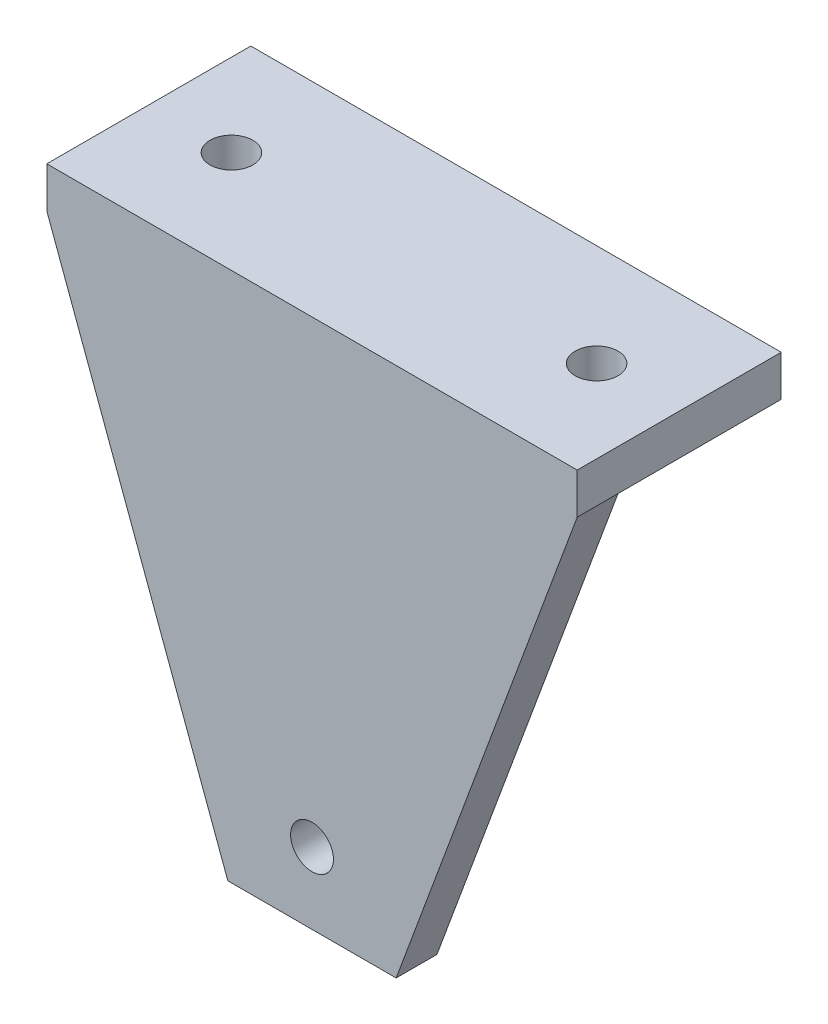
from build123d import *

# Parameters (mm, degrees)
SKETCH1_W           = 52
SKETCH1_H           = 20
SKETCH1_R           = 2.1
BOSS_EXTRUDE1_DEPTH = 4
SKETCH2_W           = 52
SKETCH2_H           = 4
BOSS_EXTRUDE2_DEPTH = 48
CUT_EXTRUDE1_REACH  = 22
SKETCH3_R           = 2.1
BOSS_EXTRUDE3_DEPTH = 16
CUT_EXTRUDE3_DEPTH  = 53


with BuildPart() as part:
    # Sketch1 → Boss-Extrude1 (new body)
    with BuildSketch(Plane(origin=(0, 0, 0), x_dir=(1, 0, 0), z_dir=(0, 1, 0))):
        with Locations((26, 10)):
            Rectangle(SKETCH1_W, SKETCH1_H)
        with Locations((43.9, 10)):
            Circle(SKETCH1_R, mode=Mode.SUBTRACT)
        with Locations((8.1, 10)):
            Circle(SKETCH1_R, mode=Mode.SUBTRACT)
    extrude(amount=BOSS_EXTRUDE1_DEPTH)

    # Sketch2 → Boss-Extrude2 (add)
    with BuildSketch(Plane.XZ):
        with Locations((26, -2)):
            Rectangle(SKETCH2_W, SKETCH2_H)
    extrude(amount=BOSS_EXTRUDE2_DEPTH)

    # Sketch3 → Cut-Extrude1 (cut, up to next)
    with BuildSketch(Plane.XY, mode=Mode.PRIVATE) as cut_extrude1_sk1:
        with Locations((26, -41)):
            Circle(SKETCH3_R)
    cut_extrude1_tool1 = extrude(cut_extrude1_sk1.sketch, amount=-CUT_EXTRUDE1_REACH, mode=Mode.PRIVATE) & part.part
    add(cut_extrude1_tool1.solids().sort_by_distance((26, -41, 0))[0], mode=Mode.SUBTRACT)
    # Sketch3 → Cut-Extrude1 (cut, up to next)
    with BuildSketch(Plane.XY, mode=Mode.PRIVATE) as cut_extrude1_sk2:
        Polygon((52, 0), (34.25, -48), (52, -48), align=None)
    cut_extrude1_tool2 = extrude(cut_extrude1_sk2.sketch, amount=-CUT_EXTRUDE1_REACH, mode=Mode.PRIVATE) & part.part
    add(cut_extrude1_tool2.solids().sort_by_distance((46.083333, -32, 0))[0], mode=Mode.SUBTRACT)
    # Sketch3 → Cut-Extrude1 (cut, up to next)
    with BuildSketch(Plane.XY, mode=Mode.PRIVATE) as cut_extrude1_sk3:
        Polygon((0, -48), (0, 0), (17.75, -48), align=None)
    cut_extrude1_tool3 = extrude(cut_extrude1_sk3.sketch, amount=-CUT_EXTRUDE1_REACH, mode=Mode.PRIVATE) & part.part
    add(cut_extrude1_tool3.solids().sort_by_distance((5.916667, -32, 0))[0], mode=Mode.SUBTRACT)

    # Sketch5 → Boss-Extrude3 (add)
    with BuildSketch(Plane(origin=(0, 0, -4), x_dir=(-1, 0, 0), z_dir=(0, 0, -1))):
        Polygon((-34.25, -48), (-38.012268219, 0), (-34, 0), (-30.237731781, -48), align=None)
        Polygon((-13.987731781, 0), (-18, 0), (-21.762268219, -48), (-17.75, -48), align=None)
    extrude(amount=BOSS_EXTRUDE3_DEPTH)

    # Sketch6 → Cut-Extrude3 (cut, through all)
    with BuildSketch(Plane.ZY):
        Polygon((-20, 0), (-4, -48), (-20, -48), align=None)
    extrude(amount=-CUT_EXTRUDE3_DEPTH, mode=Mode.SUBTRACT)


solid = part.part
